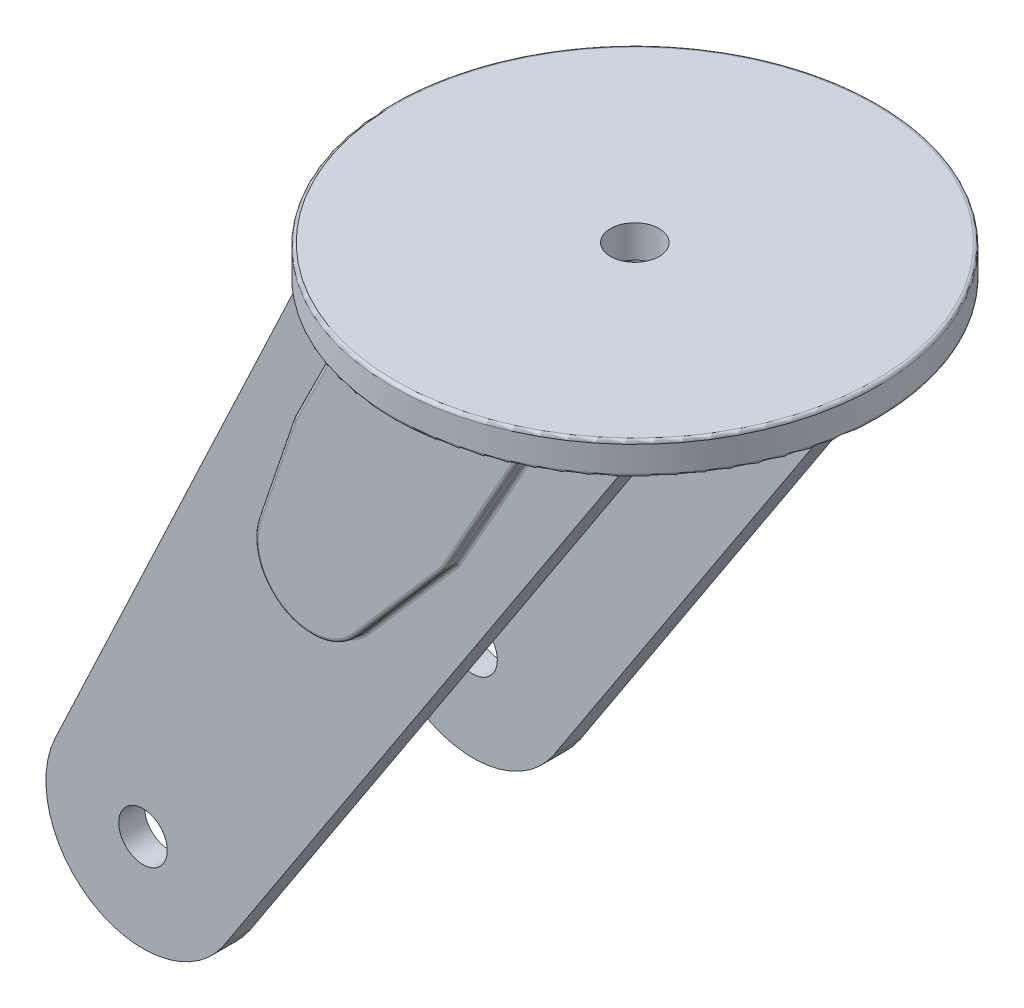
from build123d import *

# Parameters (mm, degrees)
SKETCH1_R            = 75
BOSS_EXTRUDE1_DEPTH  = 10
FILLET1_R            = 1
SKETCH2_R            = 7.5
BOSS_EXTRUDE2_DEPTH  = 8
BOSS_EXTRUDE3_DEPTH  = 4
FILLET2_R            = 1
CUT_EXTRUDE1_DEPTH   = 4
FILLET3_R            = 1
FILLET3_OF_MIRROR1_R = 1
SKETCH5_R            = 7.5
CUT_EXTRUDE2_DEPTH   = 211


with BuildPart() as part:
    # Sketch1 → Boss-Extrude1 (new body)
    with BuildSketch(Plane(origin=(0, 0, 0), x_dir=(1, 0, 0), z_dir=(0, 1, 0))):
        Circle(SKETCH1_R)
    extrude(amount=BOSS_EXTRUDE1_DEPTH)

    # Fillet1
    fillet1_edges = [part.edges().sort_by_distance(p)[0] for p in [
        (-75, 0, 0),
        (-75, 10, 0),
    ]]
    fillet(fillet1_edges, radius=FILLET1_R)

    # Sketch2 → Boss-Extrude2 (add)
    with BuildSketch(Plane.XY.offset(47)):
        with BuildLine():
            Line((-50, 0), (50, 0))
            Line((50, 0), (-71.891069435, -186.417722312))
            ThreePointArc((-71.891069435, -186.417722312), (-111.641881564, -196.184256802), (-124.134191379, -157.204076501))
            Line((-124.134191379, -157.204076501), (-50, 0))
        make_face()
        with Locations((-97, -170)):
            Circle(SKETCH2_R, mode=Mode.SUBTRACT)
    boss_extrude2 = extrude(amount=BOSS_EXTRUDE2_DEPTH)

    # Sketch3 → Boss-Extrude3 (add)
    with BuildSketch(Plane.XY.offset(55)):
        with BuildLine():
            Line((27.247938565, 0), (0, -48.276438764))
            Line((0, -48.276438764), (-27.677839504, -80.111692733))
            ThreePointArc((-27.677839504, -80.111692733), (-49.621195418, -83.816667821), (-57.508726964, -63.007425758))
            Line((-57.508726964, -63.007425758), (-46.561439617, -30.578862792))
            Line((-46.561439617, -30.578862792), (-31.290446104, 0))
            Line((-31.290446104, 0), (27.247938565, 0))
        make_face()
    boss_extrude3 = extrude(amount=BOSS_EXTRUDE3_DEPTH)

    # Fillet2
    fillet2_edges = [part.edges().sort_by_distance(p)[0] for p in [
        (-38.92594286, -15.289431396, 55),
        (-52.035083291, -46.793144275, 55),
        (-46.561439617, -30.578862792, 57),
        (-49.621195418, -83.816667821, 55),
        (-13.838919752, -64.194065748, 55),
        (13.623969282, -24.138219382, 55),
        (0, -48.276438764, 57),
        (-38.92594286, -15.289431396, 59),
        (-52.035083291, -46.793144275, 59),
        (-49.621195418, -83.816667821, 59),
        (-13.838919752, -64.194065748, 59),
        (13.623969282, -24.138219382, 59),
    ]]
    fillet(fillet2_edges, radius=FILLET2_R)

    # Sketch4 → Cut-Extrude1 (cut)
    with BuildSketch(Plane(origin=(0, 0, 47), x_dir=(-1, 0, 0), z_dir=(0, 0, -1))):
        with BuildLine():
            Line((-27.247938565, 0), (0, -48.276438764))
            Line((0, -48.276438764), (27.677839504, -80.111692733))
            ThreePointArc((27.677839504, -80.111692733), (49.621195418, -83.816667821), (57.508726964, -63.007425758))
            Line((57.508726964, -63.007425758), (46.561439617, -30.578862792))
            Line((46.561439617, -30.578862792), (31.290446104, 0))
            Line((31.290446104, 0), (-27.247938565, 0))
        make_face()
    cut_extrude1 = extrude(amount=-CUT_EXTRUDE1_DEPTH, mode=Mode.SUBTRACT)

    # Fillet3
    fillet3_edges = [part.edges().sort_by_distance(p)[0] for p in [
        (-38.92594286, -15.289431396, 51),
        (-52.035083291, -46.793144275, 51),
        (-46.561439617, -30.578862792, 49),
        (-49.621195418, -83.816667821, 51),
        (-13.838919752, -64.194065748, 51),
        (13.623969282, -24.138219382, 51),
        (0, -48.276438764, 49),
        (13.623969282, -24.138219382, 47),
        (-13.838919752, -64.194065748, 47),
        (-49.621195418, -83.816667821, 47),
        (-52.035083291, -46.793144275, 47),
        (-38.92594286, -15.289431396, 47),
    ]]
    fillet(fillet3_edges, radius=FILLET3_R)

    # Mirror1: Boss-Extrude2, Boss-Extrude3, Cut-Extrude1 across plane
    add(boss_extrude2.mirror(Plane.XY))
    add(boss_extrude3.mirror(Plane.XY))
    add(cut_extrude1.mirror(Plane.XY), mode=Mode.SUBTRACT)

    # Fillet3 of Mirror1
    fillet3_of_mirror1_edges = [part.edges().sort_by_distance(p)[0] for p in [
        (-38.92594286, -15.289431396, -51),
        (-52.035083291, -46.793144275, -51),
        (-46.561439617, -30.578862792, -49),
        (-49.621195418, -83.816667821, -51),
        (-13.838919752, -64.194065748, -51),
        (13.623969282, -24.138219382, -51),
        (0, -48.276438764, -49),
        (13.623969282, -24.138219382, -47),
        (-13.838919752, -64.194065748, -47),
        (-49.621195418, -83.816667821, -47),
        (-52.035083291, -46.793144275, -47),
        (-38.92594286, -15.289431396, -47),
    ]]
    fillet(fillet3_of_mirror1_edges, radius=FILLET3_OF_MIRROR1_R)

    # Sketch5 → Cut-Extrude2 (cut, through all)
    with BuildSketch(Plane(origin=(0, 10, 0), x_dir=(1, 0, 0), z_dir=(0, 1, 0))):
        Circle(SKETCH5_R)
    extrude(amount=-CUT_EXTRUDE2_DEPTH, mode=Mode.SUBTRACT)


solid = part.part
